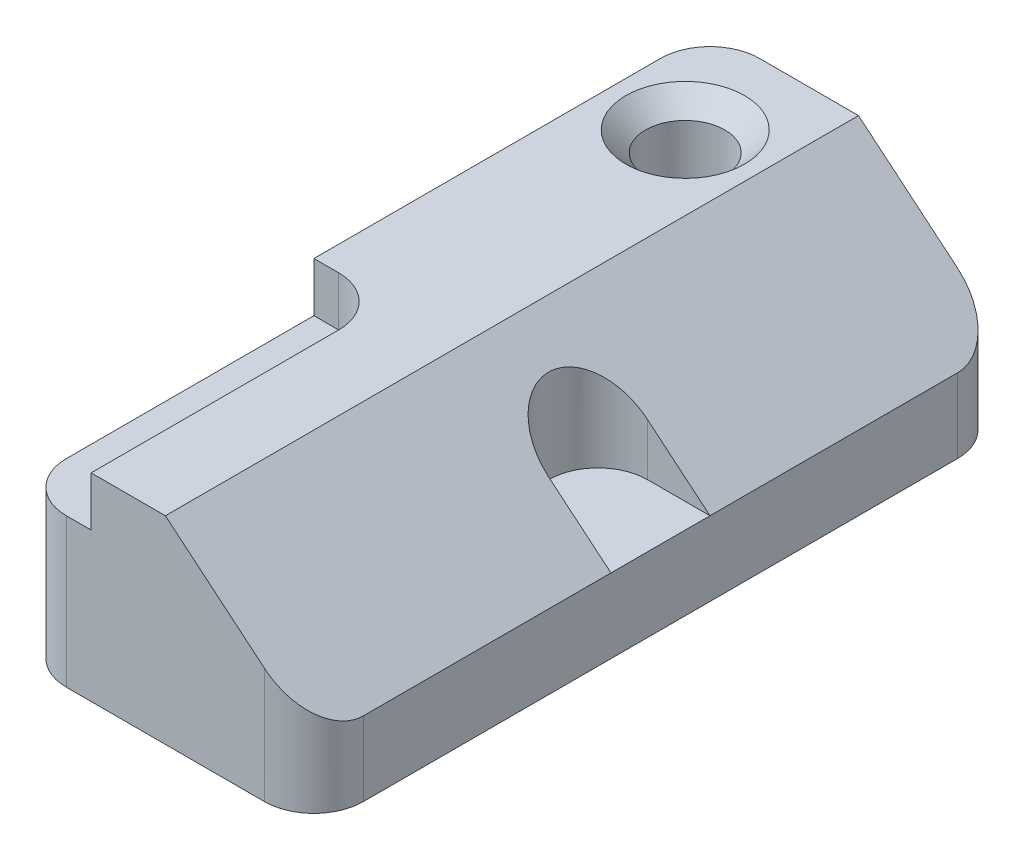
from build123d import *

# Parameters (mm, degrees)
BOSS_EXTRUDE1_DEPTH = 177.8
SKETCH2_R           = 10.16
CUT_EXTRUDE1_DEPTH  = 51.8
CHAMFER1_SIZE       = 5.08
SKETCH3_W           = 19.05
SKETCH3_H           = 76.2
CUT_EXTRUDE2_DEPTH  = 12.7
FILLET1_R           = 12.7
FILLET2_R           = 12.7
CUT_EXTRUDE8_DEPTH  = 31.75


with BuildPart() as part:
    # Sketch1 → Boss-Extrude1 (new body)
    with BuildSketch(Plane.XY):
        Polygon((0, 0), (76.2, 0), (76.2, 19.05), (38.1, 50.8), (0, 50.8), align=None)
    extrude(amount=BOSS_EXTRUDE1_DEPTH)

    # Sketch2 → Cut-Extrude1 (cut, through all)
    with BuildSketch(Plane(origin=(0, 50.8, 0), x_dir=(1, 0, 0), z_dir=(0, 1, 0))):
        with Locations((19.05, -25.4)):
            Circle(SKETCH2_R)
    extrude(amount=-CUT_EXTRUDE1_DEPTH, mode=Mode.SUBTRACT)

    # Chamfer1
    chamfer1_edges = [part.edges().sort_by_distance(p)[0] for p in [
        (8.89, 50.8, 25.4),
    ]]
    chamfer(chamfer1_edges, length=CHAMFER1_SIZE)

    # Sketch3 → Cut-Extrude2 (cut)
    with BuildSketch(Plane(origin=(0, 50.8, 0), x_dir=(1, 0, 0), z_dir=(0, 1, 0))):
        with Locations((9.525, -139.7)):
            Rectangle(SKETCH3_W, SKETCH3_H)
    extrude(amount=-CUT_EXTRUDE2_DEPTH, mode=Mode.SUBTRACT)

    # Fillet1
    fillet1_edges = [part.edges().sort_by_distance(p)[0] for p in [
        (19.05, 44.45, 101.6),
    ]]
    fillet(fillet1_edges, radius=FILLET1_R)

    # Fillet2
    fillet2_edges = [part.edges().sort_by_distance(p)[0] for p in [
        (76.2, 9.525, 177.8),
        (0, 19.05, 177.8),
        (76.2, 9.525, 0),
        (0, 25.4, 0),
    ]]
    fillet(fillet2_edges, radius=FILLET2_R)

    # Sketch17 → Cut-Extrude8 (cut)
    with BuildSketch(Plane(origin=(0, 50.8, 0), x_dir=(1, 0, 0), z_dir=(0, 1, 0))):
        with BuildLine():
            Line((76.2, -76.2), (60.198, -76.2))
            ThreePointArc((60.198, -76.2), (47.498, -88.9), (60.198, -101.6))
            Line((60.198, -101.6), (76.2, -101.6))
            Line((76.2, -101.6), (76.2, -76.2))
        make_face()
    extrude(amount=-CUT_EXTRUDE8_DEPTH, mode=Mode.SUBTRACT)


solid = part.part
